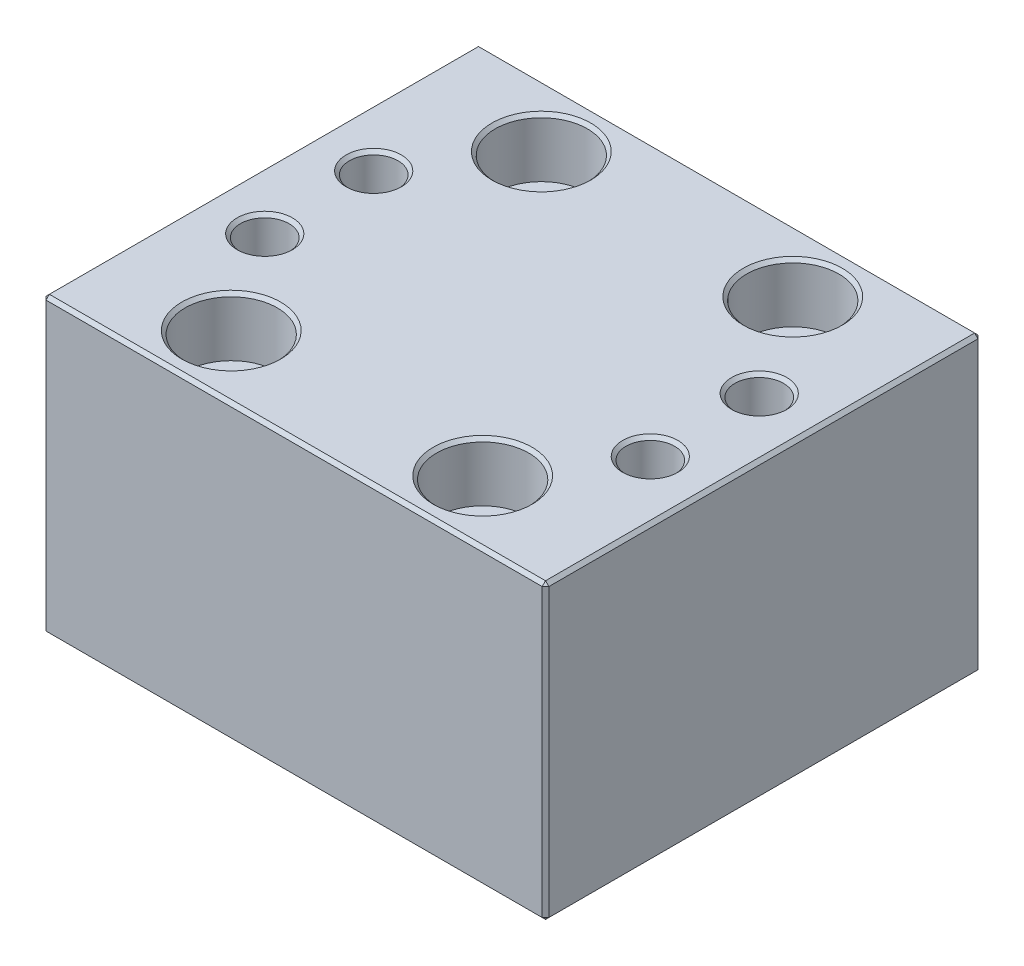
from build123d import *

# Parameters (mm, degrees)
SKETCH1_W           = 60
SKETCH1_H           = 52
SKETCH1_R           = 2.9
SKETCH1_R_2         = 3.05
BOSS_EXTRUDE1_DEPTH = 35
SKETCH2_R           = 5.5
CUT_EXTRUDE1_DEPTH  = 7
CHAMFER1_SIZE       = 0.4


with BuildPart() as part:
    # Sketch1 → Boss-Extrude1 (new body)
    with BuildSketch(Plane(origin=(0, 0, 0), x_dir=(1, 0, 0), z_dir=(0, 1, 0))):
        Rectangle(SKETCH1_W, SKETCH1_H)
        with Locations((-23, 6.5)):
            Circle(SKETCH1_R, mode=Mode.SUBTRACT)
        with Locations((23, 6.5)):
            Circle(SKETCH1_R, mode=Mode.SUBTRACT)
        with Locations((23, -6.5)):
            Circle(SKETCH1_R, mode=Mode.SUBTRACT)
        with Locations((-23, -6.5)):
            Circle(SKETCH1_R, mode=Mode.SUBTRACT)
        with Locations((-15, 18.5)):
            Circle(SKETCH1_R_2, mode=Mode.SUBTRACT)
        with Locations((15, 18.5)):
            Circle(SKETCH1_R_2, mode=Mode.SUBTRACT)
        with Locations((15, -18.5)):
            Circle(SKETCH1_R_2, mode=Mode.SUBTRACT)
        with Locations((-15, -18.5)):
            Circle(SKETCH1_R_2, mode=Mode.SUBTRACT)
    extrude(amount=BOSS_EXTRUDE1_DEPTH)

    # Sketch2 → Cut-Extrude1 (cut)
    with BuildSketch(Plane(origin=(0, 35, 0), x_dir=(1, 0, 0), z_dir=(0, 1, 0))):
        with Locations((-15, 18.5)):
            Circle(SKETCH2_R)
        with Locations((15, 18.5)):
            Circle(SKETCH2_R)
        with Locations((15, -18.5)):
            Circle(SKETCH2_R)
        with Locations((-15, -18.5)):
            Circle(SKETCH2_R)
    extrude(amount=-CUT_EXTRUDE1_DEPTH, mode=Mode.SUBTRACT)

    # Chamfer1
    chamfer1_edges = [part.edges().sort_by_distance(p)[0] for p in [
        (-25.9, 35, -6.5),
        (30, 35, 0),
        (20.1, 35, -6.5),
        (0, 35, -26),
        (20.1, 35, 6.5),
        (-25.9, 35, 6.5),
        (-30, 35, 0),
        (0, 0, -26),
        (-20.5, 35, 18.5),
        (30, 0, 0),
        (9.5, 35, 18.5),
        (9.5, 35, -18.5),
        (0, 0, 26),
        (-20.5, 35, -18.5),
        (-30, 0, 0),
        (-30, 17.5, -26),
        (30, 17.5, -26),
        (30, 17.5, 26),
        (-30, 17.5, 26),
        (0, 35, 26),
    ]]
    chamfer(chamfer1_edges, length=CHAMFER1_SIZE)


solid = part.part
